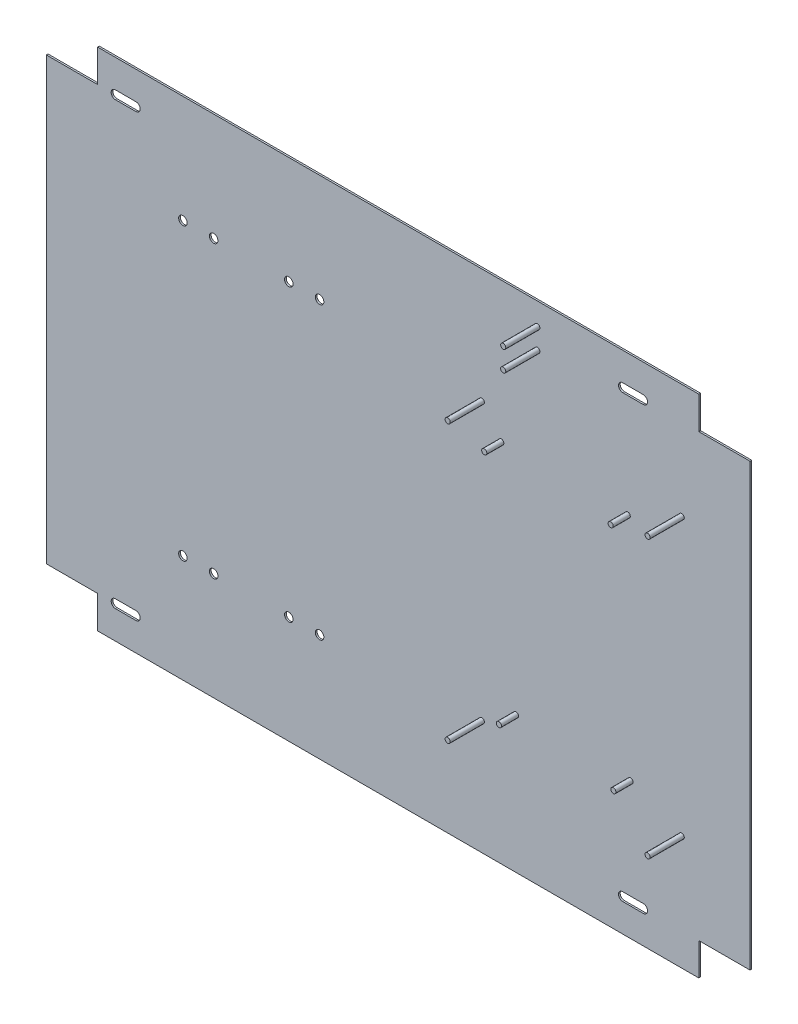
from build123d import *

# Parameters (mm, degrees)
SALIENTE_EXTRUIR1_DEPTH = 1
CORTAR_EXTRUIR1_DEPTH   = 1
CROQUIS3_R              = 1.5
SALIENTE_EXTRUIR5_DEPTH = 20
CROQUIS4_R              = 1.5
SALIENTE_EXTRUIR6_DEPTH = 10
CROQUIS5_R              = 2.5
CORTAR_EXTRUIR2_DEPTH   = 1
CROQUIS7_R              = 1.5
SALIENTE_EXTRUIR7_DEPTH = 20


with BuildPart() as part:
    # Croquis1 → Saliente-Extruir1 (new body)
    with BuildSketch(Plane.XY):
        Polygon((-30, 279), (-382, 279), (-382, 260), (-412, 260), (-412, 2), (-382, 2), (-382, -17), (-30, -17), (-30, 2), (0, 2), (0, 260), (-30, 260), align=None)
        with BuildLine():
            Line((-371.5, 262.5), (-359.5, 262.5))
            ThreePointArc((-359.5, 262.5), (-357, 260), (-359.5, 257.5))
            Line((-359.5, 257.5), (-371.5, 257.5))
            ThreePointArc((-371.5, 257.5), (-374, 260), (-371.5, 262.5))
        make_face(mode=Mode.SUBTRACT)
        with BuildLine():
            Line((-371.5, -0.5), (-359.5, -0.5))
            ThreePointArc((-359.5, -0.5), (-357, 2), (-359.5, 4.5))
            Line((-359.5, 4.5), (-371.5, 4.5))
            ThreePointArc((-371.5, 4.5), (-374, 2), (-371.5, -0.5))
        make_face(mode=Mode.SUBTRACT)
    extrude(amount=SALIENTE_EXTRUIR1_DEPTH)

    # Croquis2 → Cortar-Extruir1 (cut)
    with BuildSketch(Plane.XY.offset(1)):
        with BuildLine():
            Line((-62.5, 257.5), (-74.5, 257.5))
            ThreePointArc((-74.5, 257.5), (-77, 260), (-74.5, 262.5))
            Line((-74.5, 262.5), (-62.5, 262.5))
            ThreePointArc((-62.5, 262.5), (-60, 260), (-62.5, 257.5))
        make_face()
        with BuildLine():
            Line((-62.5, 4.5), (-74.5, 4.5))
            ThreePointArc((-74.5, 4.5), (-77, 2), (-74.5, -0.5))
            Line((-74.5, -0.5), (-62.5, -0.5))
            ThreePointArc((-62.5, -0.5), (-60, 2), (-62.5, 4.5))
        make_face()
    extrude(amount=-CORTAR_EXTRUIR1_DEPTH, mode=Mode.SUBTRACT)

    # Croquis3 → Saliente-Extruir5 (add)
    with BuildSketch(Plane.XY.offset(1)):
        with Locations((-40, 212)):
            Circle(CROQUIS3_R)
        with Locations((-40, 50)):
            Circle(CROQUIS3_R)
        with Locations((-157, 50)):
            Circle(CROQUIS3_R)
        with Locations((-157, 212)):
            Circle(CROQUIS3_R)
    extrude(amount=SALIENTE_EXTRUIR5_DEPTH)

    # Croquis4 → Saliente-Extruir6 (add)
    with BuildSketch(Plane.XY.offset(1)):
        with Locations((-71.6, 197)):
            Circle(CROQUIS4_R)
        with Locations((-70, 63)):
            Circle(CROQUIS4_R)
        with Locations((-137, 63)):
            Circle(CROQUIS4_R)
        with Locations((-145.6, 197)):
            Circle(CROQUIS4_R)
    extrude(amount=SALIENTE_EXTRUIR6_DEPTH)

    # Croquis5 → Cortar-Extruir2 (cut)
    with BuildSketch(Plane.XY.offset(1)):
        with Locations((-332, 216)):
            Circle(CROQUIS5_R)
        with Locations((-332, 46)):
            Circle(CROQUIS5_R)
        with Locations((-314, 216)):
            Circle(CROQUIS5_R)
        with Locations((-314, 46)):
            Circle(CROQUIS5_R)
        with Locations((-270, 46)):
            Circle(CROQUIS5_R)
        with Locations((-252, 46)):
            Circle(CROQUIS5_R)
        with Locations((-270, 216)):
            Circle(CROQUIS5_R)
        with Locations((-252, 216)):
            Circle(CROQUIS5_R)
    extrude(amount=-CORTAR_EXTRUIR2_DEPTH, mode=Mode.SUBTRACT)

    # Croquis7 → Saliente-Extruir7 (add)
    with BuildSketch(Plane.XY.offset(1)):
        with Locations((-124.5, 266)):
            Circle(CROQUIS7_R)
        with Locations((-124.5, 254)):
            Circle(CROQUIS7_R)
    extrude(amount=SALIENTE_EXTRUIR7_DEPTH)


solid = part.part
